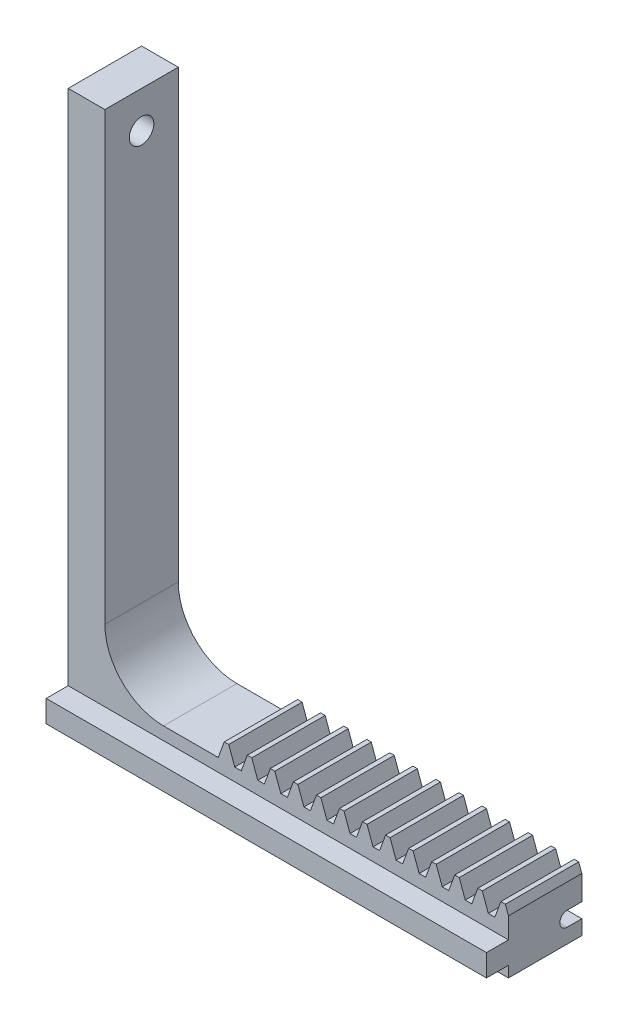
from build123d import *

# Parameters (mm, degrees)
BLANKSKE_W          = 40
BLANKSKE_H          = 8.5
BLANK_DEPTH         = 10
TOOTHCUTSIM_DEPTH   = 43.09809972
TEETHCUTS_COUNT     = 14
TEETHCUTS_PITCH     = 3.14159265
BOSS_EXTRUDE1_DEPTH = 10
SKETCH2_W           = 3
SKETCH2_H           = 3
BOSS_EXTRUDE2_DEPTH = 60
CUT_EXTRUDE2_DEPTH  = 97.566039579
MOVE_FACE2_BY       = 5
FILLET2_R           = 8
SKETCH3_R           = 1.675
CUT_EXTRUDE1_DEPTH  = 94.541434669


with BuildPart() as part:
    # BlankSke → Blank (new body)
    with BuildSketch(Plane.XY):
        with Locations((20, 4.25)):
            Rectangle(BLANKSKE_W, BLANKSKE_H)
    extrude(amount=-BLANK_DEPTH)

    # TooCutSkeSim → ToothCutSim (cut, through all)
    with BuildSketch(Plane.XY):
        Polygon((0.44443537, 6.25), (-0.44443537, 6.25), (-1.272613241, 8.5254), (1.272613241, 8.5254), align=None)
    toothcutsim = extrude(amount=-TOOTHCUTSIM_DEPTH, mode=Mode.SUBTRACT)

    # TeethCuts: ToothCutSim ×14
    with Locations(*[(i * TEETHCUTS_PITCH, 0, 0) for i in range(1, TEETHCUTS_COUNT)]):
        add(toothcutsim, mode=Mode.SUBTRACT)

    # Sketch1 → Boss-Extrude1 (add)
    with BuildSketch(Plane.XY):
        Polygon((0, 0), (-20, 0), (-20, 75), (-10, 75), (-10, 6.25), (0, 6.25), align=None)
    extrude(amount=-BOSS_EXTRUDE1_DEPTH)

    # Sketch2 → Boss-Extrude2 (add)
    with BuildSketch(Plane(origin=(40, 0, 0), x_dir=(0, 0, -1), z_dir=(1, 0, 0))):
        with Locations((-1.5, 3)):
            Rectangle(SKETCH2_W, SKETCH2_H)
    extrude(amount=-BOSS_EXTRUDE2_DEPTH)

    # Sketch5 → Cut-Extrude2 (cut, through all)
    with BuildSketch(Plane(origin=(40, 0, 0), x_dir=(0, 0, -1), z_dir=(1, 0, 0))):
        with BuildLine():
            Line((10, 4), (8, 4))
            ThreePointArc((8, 4), (7, 3), (8, 2))
            Line((8, 2), (10, 2))
            Line((10, 2), (10, 4))
        make_face()
    extrude(amount=-CUT_EXTRUDE2_DEPTH, mode=Mode.SUBTRACT)

    # Move Face2: a face moved inward by 5.0
    extrude(part.faces().sort_by_distance((-10, 40.625, -5))[0], amount=MOVE_FACE2_BY, dir=(-1, 0, 0), mode=Mode.SUBTRACT)

    # Fillet2
    fillet2_edges = [part.edges().sort_by_distance(p)[0] for p in [
        (-15, 6.25, -5),
    ]]
    fillet(fillet2_edges, radius=FILLET2_R)

    # Sketch3 → Cut-Extrude1 (cut, through all)
    with BuildSketch(Plane.ZY.offset(15)):
        with Locations(Location((-5, 70, 0), (0, 0, 90))):
            Circle(SKETCH3_R)
    extrude(amount=CUT_EXTRUDE1_DEPTH, mode=Mode.SUBTRACT)


solid = part.part
